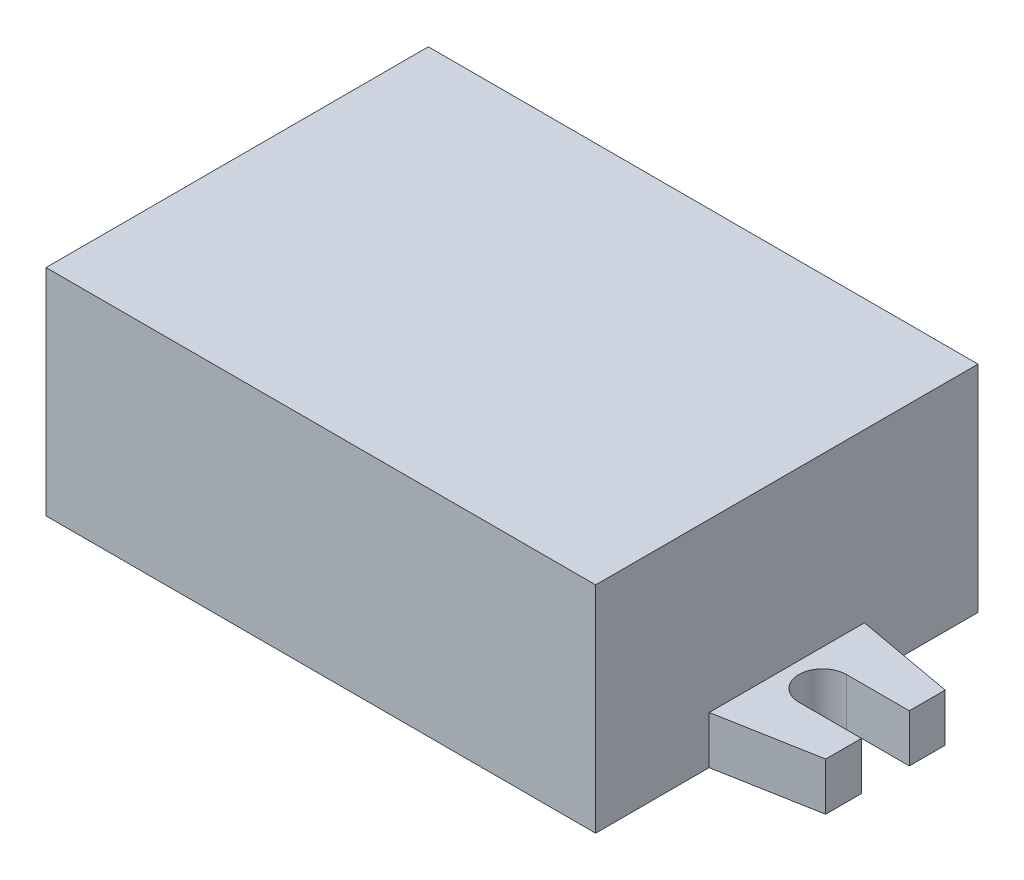
from build123d import *

# Parameters (mm, degrees)
SKETCH1_W           = 23
SKETCH1_H           = 32
BOSS_EXTRUDE1_DEPTH = 18
BOSS_EXTRUDE2_DEPTH = 4


with BuildPart() as part:
    # Sketch1 → Boss-Extrude1 (new body)
    with BuildSketch(Plane(origin=(0, 0, 0), x_dir=(1, 0, 0), z_dir=(0, 1, 0))):
        with Locations((-11.5, 0)):
            Rectangle(SKETCH1_W, SKETCH1_H)
    boss_extrude1 = extrude(amount=BOSS_EXTRUDE1_DEPTH)

    # Sketch2 → Boss-Extrude2 (add)
    with BuildSketch(Plane.XZ):
        with BuildLine():
            Line((-31.25, -5), (-31.25, -2))
            Line((-31.25, -2), (-26, -2))
            ThreePointArc((-26, -2), (-24, 0), (-26, 2))
            Line((-26, 2), (-31.25, 2))
            Line((-31.25, 2), (-31.25, 5))
            Line((-31.25, 5), (-23, 6.5))
            Line((-23, 6.5), (-23, -6.5))
            Line((-23, -6.5), (-31.25, -5))
        make_face()
    boss_extrude2 = extrude(amount=-BOSS_EXTRUDE2_DEPTH)

    # Mirror1: Boss-Extrude1, Boss-Extrude2 across plane
    add(boss_extrude1.mirror(Plane(origin=(0, 18, 16), x_dir=(0, 0, 1), z_dir=(-1, 0, 0))))
    add(boss_extrude2.mirror(Plane(origin=(0, 18, 16), x_dir=(0, 0, 1), z_dir=(-1, 0, 0))))


solid = part.part
